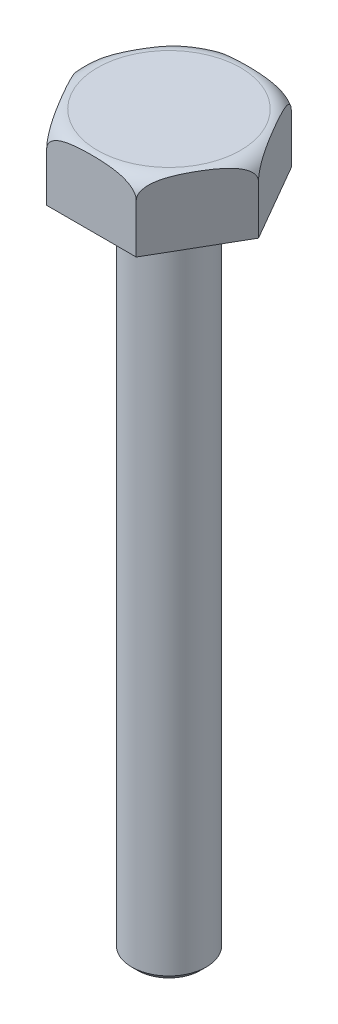
from build123d import *

# Parameters (mm, degrees)
SKETCH3_R           = 25
BOSS_EXTRUDE2_DEPTH = 445
BOSS_EXTRUDE3_DEPTH = 45
CHAMFER2_SIZE       = 4


with BuildPart() as part:
    # Sketch3 → Boss-Extrude2 (new body)
    with BuildSketch(Plane(origin=(0, 0, 0), x_dir=(1, 0, 0), z_dir=(0, 1, 0))):
        Circle(SKETCH3_R)
    extrude(amount=BOSS_EXTRUDE2_DEPTH)

    # Sketch4 → Boss-Extrude3 (add)
    with BuildSketch(Plane(origin=(0, 445, 0), x_dir=(1, 0, 0), z_dir=(0, 1, 0))):
        Polygon((60.044427996, 0), (30.022213998, 52), (-30.022213998, 52), (-60.044427996, 0), (-30.022213998, -52), (30.022213998, -52), align=None)
    extrude(amount=BOSS_EXTRUDE3_DEPTH)

    # Chamfer2
    chamfer2_edges = [part.edges().sort_by_distance(p)[0] for p in [
        (-25, 0, 0),
    ]]
    chamfer(chamfer2_edges, length=CHAMFER2_SIZE)

    # Sketch5 → Cut-Revolve1 (revolve, cut)
    with BuildSketch(Plane.XY):
        with BuildLine():
            Line((-48.044427996, 490), (-42.422825607, 490))
            Line((-42.422825607, 490), (-58.618044672, 506.195219065))
            Line((-58.618044672, 506.195219065), (-76.909784041, 483.543059665))
            Line((-76.909784041, 483.543059665), (-60.044427996, 474.029415959))
            Line((-60.044427996, 474.029415959), (-60.044427996, 478))
            ThreePointArc((-60.044427996, 478), (-56.52970937, 486.485281374), (-48.044427996, 490))
        make_face()
    revolve(axis=Axis((0, 490.810426385, 0), (0, 1, 0)), mode=Mode.SUBTRACT)


solid = part.part
